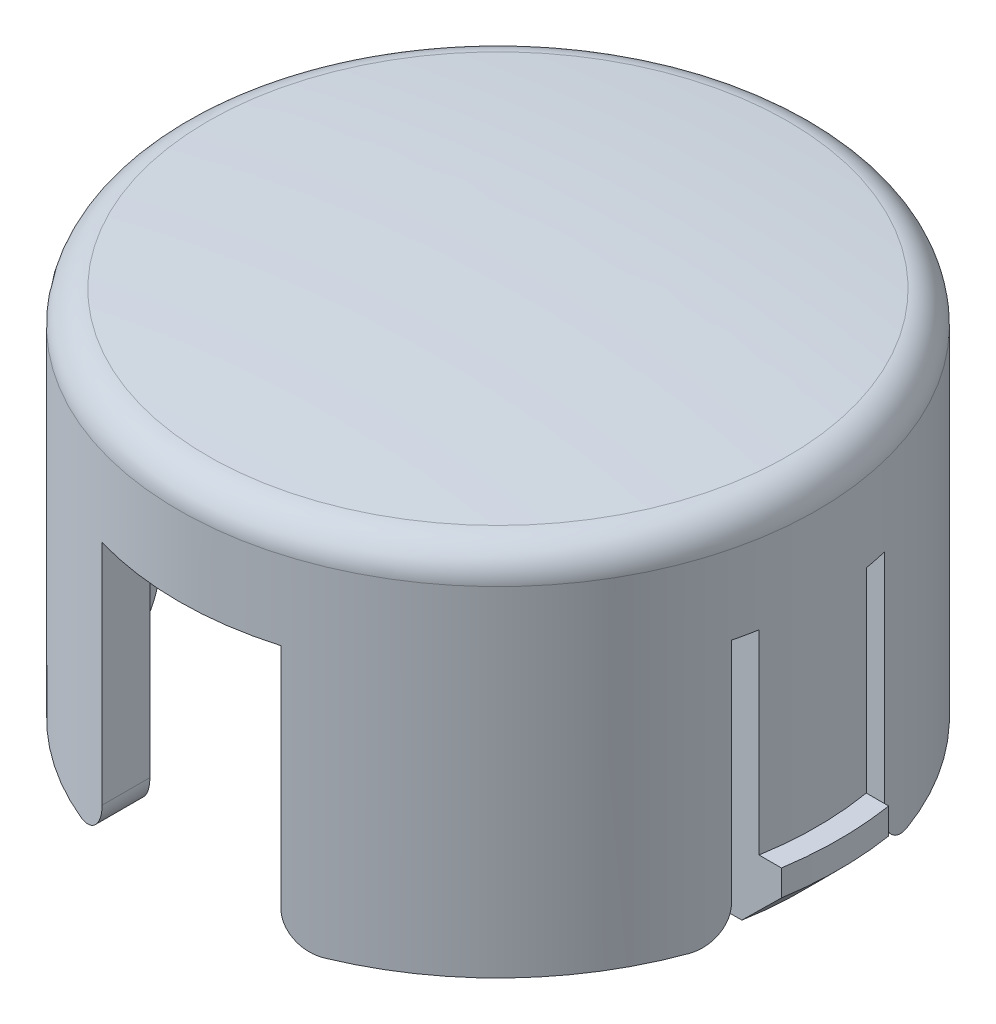
from build123d import *

# Parameters (mm, degrees)
SKETCH2_W     = 6.985
SKETCH2_H     = 32.356336156
SKETCH2_W_2   = 40.972237954
SKETCH2_H_2   = 0.889
CUTOUT_DEPTH  = 10.16
TAB_DEPTH     = 2.54
TAB_CHMF_SIZE = 1.524
CROSS_DEPTH   = 7.62
SKETCH4_W     = 3.302
SKETCH4_H     = 7.6962
BOX_DEPTH     = 13.059399
SKETCH6_W     = 1.778
SKETCH6_H     = 6.1722
BOXCUT_DEPTH  = 13.059399
FILLET1_R     = 1.27


with BuildPart() as part:
    # Sketch1 → dome/base (revolve)
    with BuildSketch(Plane.XY):
        with BuildLine():
            Line((0, 6.039891065), (0, 3.960890157))
            Line((0, 3.960890157), (10.6934, 3.960890157))
            Line((10.6934, 3.960890157), (10.6934, -9.047708935))
            Line((10.6934, -9.047708935), (12.4714, -9.047708935))
            Line((12.4714, -9.047708935), (12.4714, 4.195604597))
            ThreePointArc((12.4714, 4.195604597), (12.144228327, 5.046471653), (11.33128229, 5.45894564))
            ThreePointArc((11.33128229, 5.45894564), (5.673082405, 5.894559394), (0, 6.039891065))
        make_face()
    revolve(axis=Axis((0, 0, 0), (0, 1, 0)))

    # Sketch2 → cutout (cut)
    with BuildSketch(Plane.XZ.offset(9.047708935)):
        Rectangle(SKETCH2_W, SKETCH2_H)
        with Locations((0, 2.54)):
            Rectangle(SKETCH2_W_2, SKETCH2_H_2)
        with Locations((0, -2.54)):
            Rectangle(SKETCH2_W_2, SKETCH2_H_2)
    extrude(amount=-CUTOUT_DEPTH, mode=Mode.SUBTRACT)

    # Sketch3 → tab (add)
    with BuildSketch(Plane.XZ.offset(9.047708935)):
        with BuildLine():
            Line((-13.169324385, -2.0955), (-12.294091984, -2.0955))
            ThreePointArc((-12.294091984, -2.0955), (-12.4714, 0), (-12.294091984, 2.0955))
            Line((-12.294091984, 2.0955), (-13.169324385, 2.0955))
            ThreePointArc((-13.169324385, 2.0955), (-13.335, 0), (-13.169324385, -2.0955))
        make_face()
        with BuildLine():
            Line((12.294091984, -2.0955), (13.169324385, -2.0955))
            ThreePointArc((13.169324385, -2.0955), (13.293516571, -1.051019583), (13.335, 0))
            ThreePointArc((13.335, 0), (13.293516571, 1.051019583), (13.169324385, 2.0955))
            Line((13.169324385, 2.0955), (12.294091984, 2.0955))
            ThreePointArc((12.294091984, 2.0955), (12.4714, 0), (12.294091984, -2.0955))
        make_face()
    extrude(amount=-TAB_DEPTH)

    # tab chmf
    tab_chmf_edges = [part.edges().sort_by_distance(p)[0] for p in [
        (-13.335, -9.047708935, 0),
        (13.335, -9.047708935, 0),
    ]]
    chamfer(tab_chmf_edges, length=TAB_CHMF_SIZE)

    # Sketch5 → cross (add)
    with BuildSketch(Plane.XZ.offset(-3.960890157)):
        with BuildLine():
            Line((0, -0.71842049), (-0.71842049, 0))
            Line((-0.71842049, 0), (-7.91204877, -7.19362828))
            ThreePointArc((-7.91204877, -7.19362828), (-7.561375654, -7.561375654), (-7.19362828, -7.91204877))
            Line((-7.19362828, -7.91204877), (0, -0.71842049))
        make_face()
        with BuildLine():
            Line((7.91204877, -7.19362828), (0.71842049, 0))
            Line((0.71842049, 0), (0, -0.71842049))
            Line((0, -0.71842049), (7.19362828, -7.91204877))
            ThreePointArc((7.19362828, -7.91204877), (7.561375654, -7.561375654), (7.91204877, -7.19362828))
        make_face()
        with BuildLine():
            Line((7.19362828, 7.91204877), (0, 0.71842049))
            Line((0, 0.71842049), (0.71842049, 0))
            Line((0.71842049, 0), (7.91204877, 7.19362828))
            ThreePointArc((7.91204877, 7.19362828), (7.561375654, 7.561375654), (7.19362828, 7.91204877))
        make_face()
        Polygon((0.71842049, 0), (0, 0.71842049), (-0.71842049, 0), (0, -0.71842049), align=None)
        with BuildLine():
            Line((-0.71842049, 0), (0, 0.71842049))
            Line((0, 0.71842049), (-7.19362828, 7.91204877))
            ThreePointArc((-7.19362828, 7.91204877), (-7.561375654, 7.561375654), (-7.91204877, 7.19362828))
            Line((-7.91204877, 7.19362828), (-0.71842049, 0))
        make_face()
    extrude(amount=CROSS_DEPTH)

    # Sketch4 → box (add)
    with BuildSketch(Plane.XZ.offset(-3.960890157)):
        Rectangle(SKETCH4_W, SKETCH4_H)
    extrude(amount=BOX_DEPTH)

    # Sketch6 → boxcut (cut)
    with BuildSketch(Plane.XZ.offset(9.098508935)):
        Rectangle(SKETCH6_W, SKETCH6_H)
    extrude(amount=-BOXCUT_DEPTH, mode=Mode.SUBTRACT)

    # Fillet1
    fillet1_edges = [part.edges().sort_by_distance(p)[0] for p in [
        (-3.4925, -9.047708935, -11.039692922),
        (3.4925, -9.047708935, -11.039692922),
        (11.188751506, -9.047708935, -2.9845),
        (-11.188751506, -9.047708935, -2.9845),
        (-3.4925, -9.047708935, 11.039692922),
        (3.4925, -9.047708935, 11.039692922),
        (-11.188751506, -9.047708935, 2.9845),
        (11.188751506, -9.047708935, 2.9845),
    ]]
    fillet(fillet1_edges, radius=FILLET1_R)


solid = part.part
